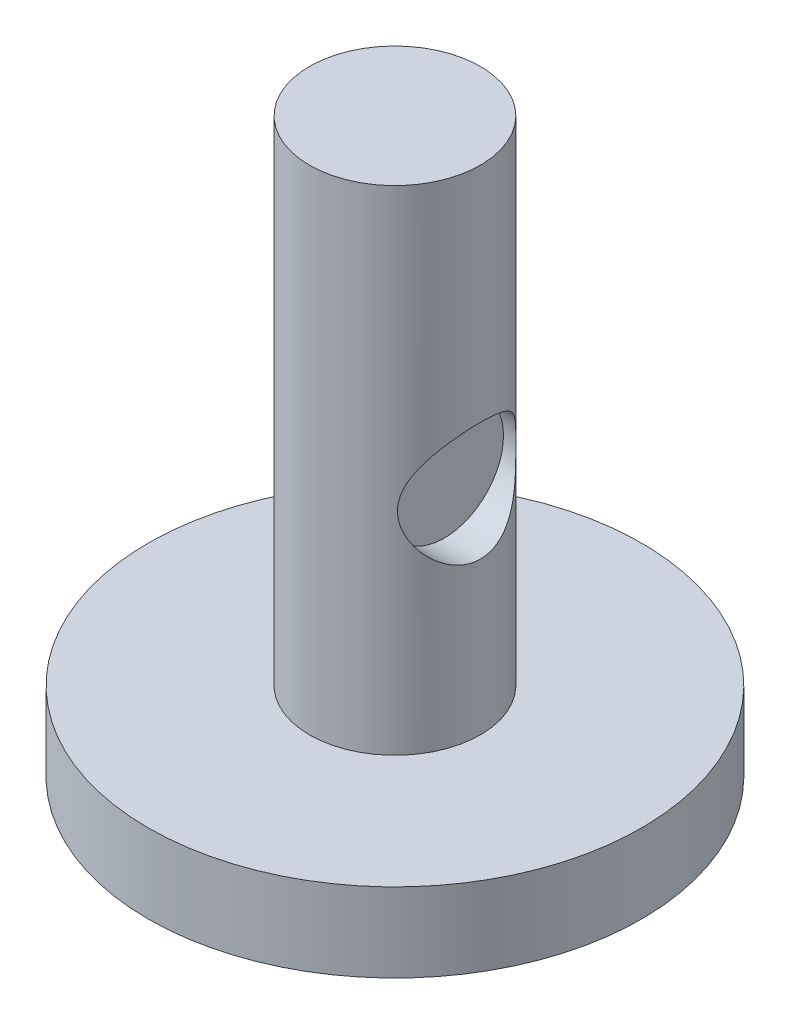
from build123d import *

# Parameters (mm, degrees)
SKETCH1_R           = 25
BOSS_EXTRUDE1_DEPTH = 8
SKETCH2_R           = 8.664977056
BOSS_EXTRUDE2_DEPTH = 50
SKETCH3_R           = 6
CUT_EXTRUDE1_DEPTH  = 15


with BuildPart() as part:
    # Sketch1 → Boss-Extrude1 (new body)
    with BuildSketch(Plane(origin=(0, 0, 0), x_dir=(1, 0, 0), z_dir=(0, 1, 0))):
        Circle(SKETCH1_R)
    extrude(amount=BOSS_EXTRUDE1_DEPTH)

    # Sketch2 → Boss-Extrude2 (add)
    with BuildSketch(Plane(origin=(0, 8, 0), x_dir=(1, 0, 0), z_dir=(0, 1, 0))):
        Circle(SKETCH2_R)
    extrude(amount=BOSS_EXTRUDE2_DEPTH)

    # Sketch3 → Cut-Extrude1 (cut)
    with BuildSketch(Plane(origin=(20, 0, 0), x_dir=(0, 0, -1), z_dir=(1, 0, 0))):
        with Locations((0, 29.42990961)):
            Circle(SKETCH3_R)
    extrude(amount=-CUT_EXTRUDE1_DEPTH, mode=Mode.SUBTRACT)


solid = part.part
